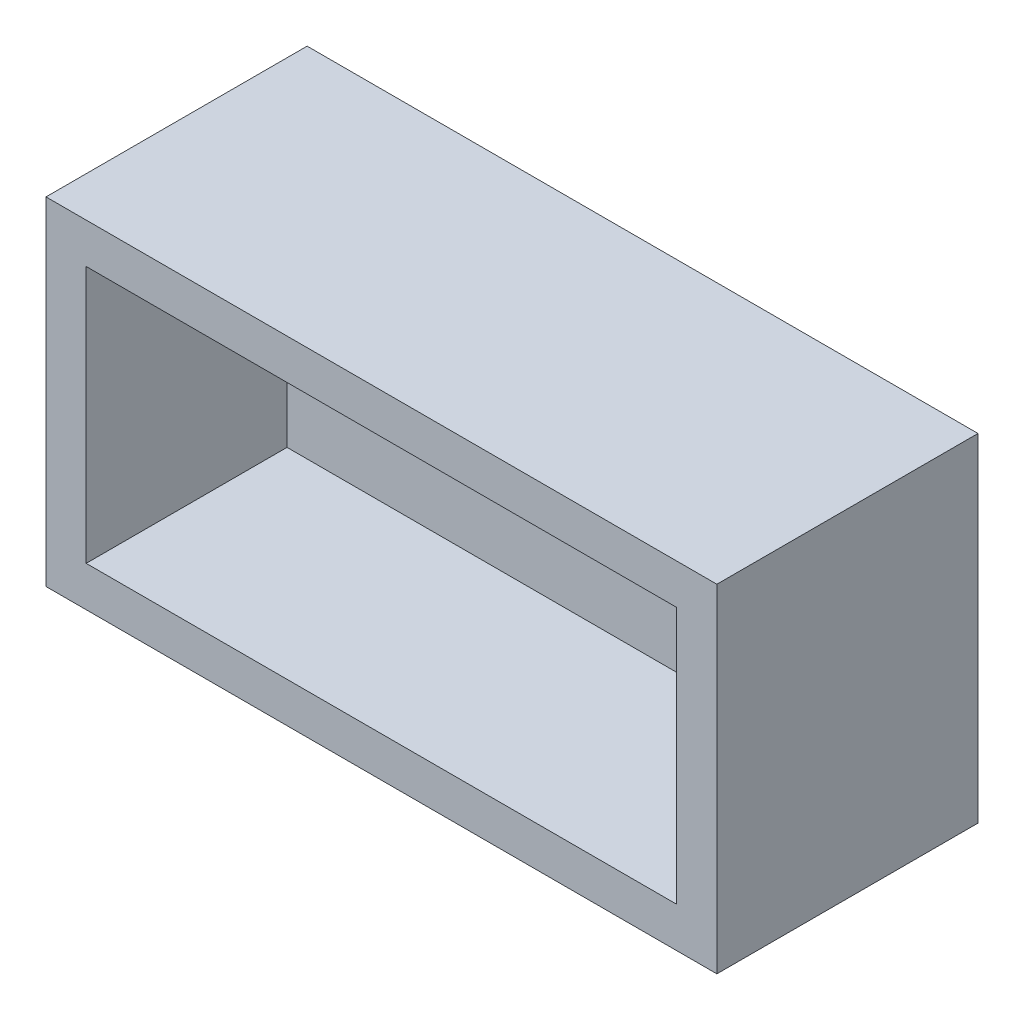
from build123d import *

# Parameters (mm, degrees)
SKETCH_2_W          = 33.4
SKETCH_2_H          = 16.8
EXTRUDE_1_DEPTH     = 13
SKETCH_3_W          = 29.4
SKETCH_3_H          = 12.8
CUT_EXTRUDE_1_DEPTH = 10


with BuildPart() as part:
    # Эскиз2 → Бобышка-Вытянуть1 (new body)
    with BuildSketch(Plane.XY):
        Rectangle(SKETCH_2_W, SKETCH_2_H)
    extrude(amount=EXTRUDE_1_DEPTH)

    # Эскиз3 → Вырез-Вытянуть1 (cut)
    with BuildSketch(Plane.XY.offset(13)):
        Rectangle(SKETCH_3_W, SKETCH_3_H)
    extrude(amount=-CUT_EXTRUDE_1_DEPTH, mode=Mode.SUBTRACT)


solid = part.part
